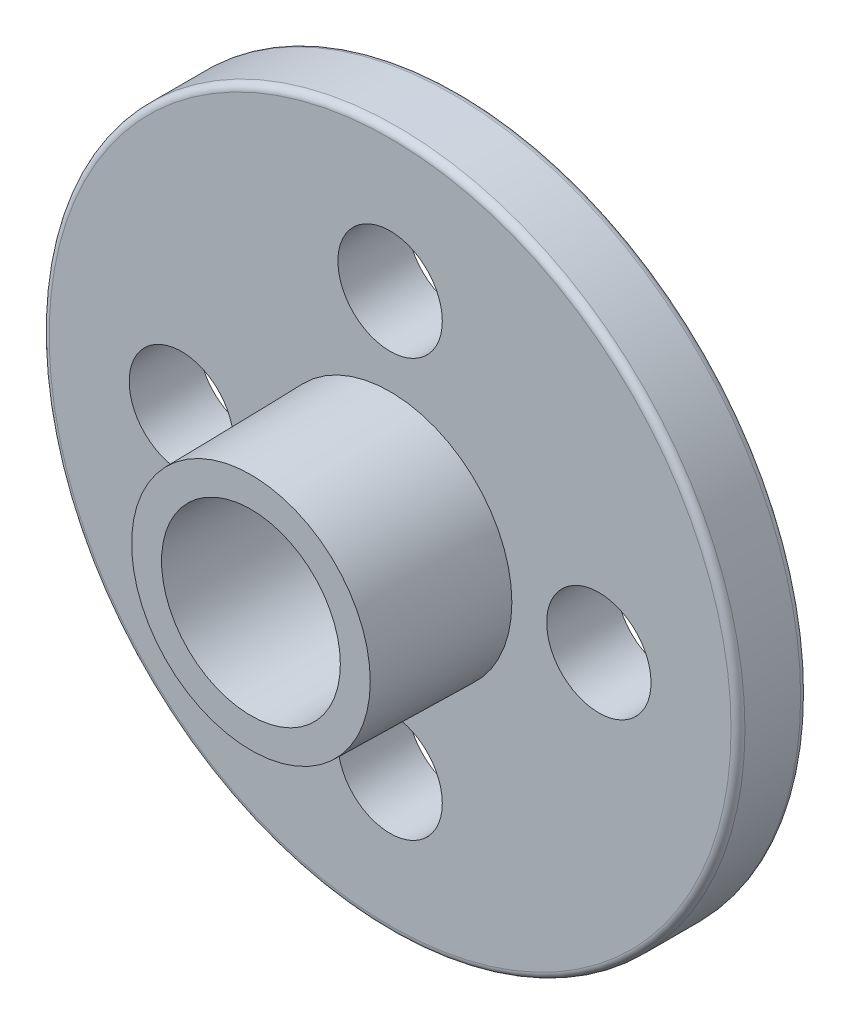
from build123d import *

# Parameters (mm, degrees)
IZIM1_R                     = 10
IZIM1_R_2                   = 1.5
Y_KSEKLIK_EKSTR_ZYON1_DEPTH = 2
RADYUS1_R                   = 0.2
IZIM2_R                     = 3.5
IZIM2_R_2                   = 2.5
Y_KSEKLIK_EKSTR_ZYON2_DEPTH = 4
Y_KSEKLIK_EKSTR_ZYON2_TAPER = 1
IZIM3_R                     = 1.5
KES_EKSTR_ZYON1_DEPTH       = 4


with BuildPart() as part:
    # Çizim1 → Yükseklik-Ekstrüzyon1 (new body)
    with BuildSketch(Plane.XY):
        Circle(IZIM1_R)
        with Locations((0, 6)):
            Circle(IZIM1_R_2, mode=Mode.SUBTRACT)
        with Locations((6, 0)):
            Circle(IZIM1_R_2, mode=Mode.SUBTRACT)
        with Locations((0, -6)):
            Circle(IZIM1_R_2, mode=Mode.SUBTRACT)
        with Locations((-6, 0)):
            Circle(IZIM1_R_2, mode=Mode.SUBTRACT)
    extrude(amount=Y_KSEKLIK_EKSTR_ZYON1_DEPTH)

    # Radyus1
    radyus1_edges = [part.edges().sort_by_distance(p)[0] for p in [
        (-10, 0, 0),
        (-10, 0, 2),
    ]]
    fillet(radyus1_edges, radius=RADYUS1_R)

    # Çizim2 → Yükseklik-Ekstrüzyon2 (add)
    with BuildSketch(Plane.XY.offset(2)):
        Circle(IZIM2_R)
        Circle(IZIM2_R_2, mode=Mode.SUBTRACT)
    extrude(amount=Y_KSEKLIK_EKSTR_ZYON2_DEPTH, taper=Y_KSEKLIK_EKSTR_ZYON2_TAPER)

    # Çizim3 → Kes-Ekstrüzyon1 (cut)
    with BuildSketch(Plane(origin=(0, 0, 0), x_dir=(-1, 0, 0), z_dir=(0, 0, -1))):
        Circle(IZIM3_R)
    extrude(amount=-KES_EKSTR_ZYON1_DEPTH, mode=Mode.SUBTRACT)


solid = part.part
